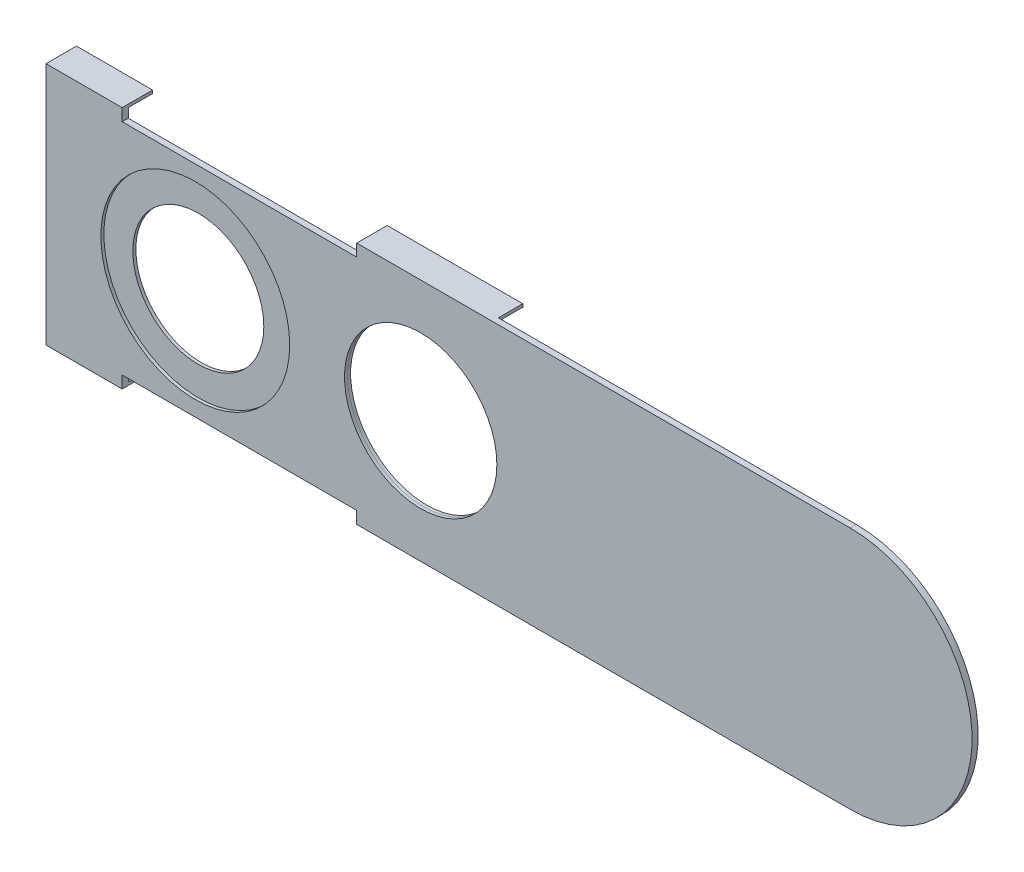
from build123d import *

# Parameters (mm, degrees)
BOSS_EXTRUDE1_DEPTH = 0.508
SKETCH2_R           = 7.874
SKETCH2_R_2         = 6.35
CUT_EXTRUDE2_DEPTH  = 0.254
SKETCH5_R           = 6.354160617
CUT_EXTRUDE3_DEPTH  = 68.821805137
SKETCH6_R           = 5.461
CUT_EXTRUDE4_DEPTH  = 68.821805137
SKETCH7_W           = 19.558
SKETCH7_H           = 1.016
CUT_EXTRUDE5_DEPTH  = 68.823232008
SKETCH8_W           = 6.35
SKETCH8_H           = 0.254
BOSS_EXTRUDE2_DEPTH = 2.032
SKETCH10_W          = 11.303182767
SKETCH10_H          = 0.254
BOSS_EXTRUDE3_DEPTH = 2.032
SKETCH11_W          = 6.35
SKETCH11_H          = 0.254
BOSS_EXTRUDE4_DEPTH = 2.032
SKETCH12_W          = 11.938
SKETCH12_H          = 0.254
BOSS_EXTRUDE5_DEPTH = 2.032


with BuildPart() as part:
    # Sketch1 → Boss-Extrude1 (new body)
    with BuildSketch(Plane.XY):
        with BuildLine():
            ThreePointArc((0, -10.16), (10.16, 0), (0, 10.16))
            Line((0, 10.16), (-67.056, 10.16))
            Line((-67.056, 10.16), (-67.056, -10.16))
            Line((-67.056, -10.16), (0, -10.16))
        make_face()
    extrude(amount=BOSS_EXTRUDE1_DEPTH)

    # Sketch2 → Cut-Extrude2 (cut)
    with BuildSketch(Plane.XY.offset(0.508)):
        with Locations((-54.61, 0)):
            Circle(SKETCH2_R)
        with Locations((-35.814, 0)):
            Circle(SKETCH2_R_2)
    extrude(amount=-CUT_EXTRUDE2_DEPTH, mode=Mode.SUBTRACT)

    # Sketch5 → Cut-Extrude3 (cut, through all)
    with BuildSketch(Plane.XY.offset(0.254)):
        with Locations((-35.814, 0)):
            Circle(SKETCH5_R)
    extrude(amount=-CUT_EXTRUDE3_DEPTH, mode=Mode.SUBTRACT)

    # Sketch6 → Cut-Extrude4 (cut, through all)
    with BuildSketch(Plane.XY.offset(0.254)):
        with Locations((-54.61, 0)):
            Circle(SKETCH6_R)
    extrude(amount=-CUT_EXTRUDE4_DEPTH, mode=Mode.SUBTRACT)

    # Sketch7 → Cut-Extrude5 (cut, through all)
    with BuildSketch(Plane(origin=(0, 0, 0), x_dir=(-1, 0, 0), z_dir=(0, 0, -1))):
        with Locations((50.927, 9.652)):
            Rectangle(SKETCH7_W, SKETCH7_H)
        with Locations((50.927, -9.652)):
            Rectangle(SKETCH7_W, SKETCH7_H)
    extrude(amount=-CUT_EXTRUDE5_DEPTH, mode=Mode.SUBTRACT)

    # Sketch8 → Boss-Extrude2 (add)
    with BuildSketch(Plane(origin=(0, 0, 0), x_dir=(-1, 0, 0), z_dir=(0, 0, -1))):
        with Locations((63.881, 10.033)):
            Rectangle(SKETCH8_W, SKETCH8_H)
    extrude(amount=BOSS_EXTRUDE2_DEPTH)

    # Sketch10 → Boss-Extrude3 (add)
    with BuildSketch(Plane(origin=(0, 0, 0), x_dir=(-1, 0, 0), z_dir=(0, 0, -1))):
        with Locations((35.496408617, 10.033)):
            Rectangle(SKETCH10_W, SKETCH10_H)
    extrude(amount=BOSS_EXTRUDE3_DEPTH)

    # Sketch11 → Boss-Extrude4 (add)
    with BuildSketch(Plane(origin=(0, 0, 0), x_dir=(-1, 0, 0), z_dir=(0, 0, -1))):
        with Locations((63.881, -10.033)):
            Rectangle(SKETCH11_W, SKETCH11_H)
    extrude(amount=BOSS_EXTRUDE4_DEPTH)

    # Sketch12 → Boss-Extrude5 (add)
    with BuildSketch(Plane(origin=(0, 0, 0), x_dir=(-1, 0, 0), z_dir=(0, 0, -1))):
        with Locations((35.179, -10.033)):
            Rectangle(SKETCH12_W, SKETCH12_H)
    extrude(amount=BOSS_EXTRUDE5_DEPTH)


solid = part.part
